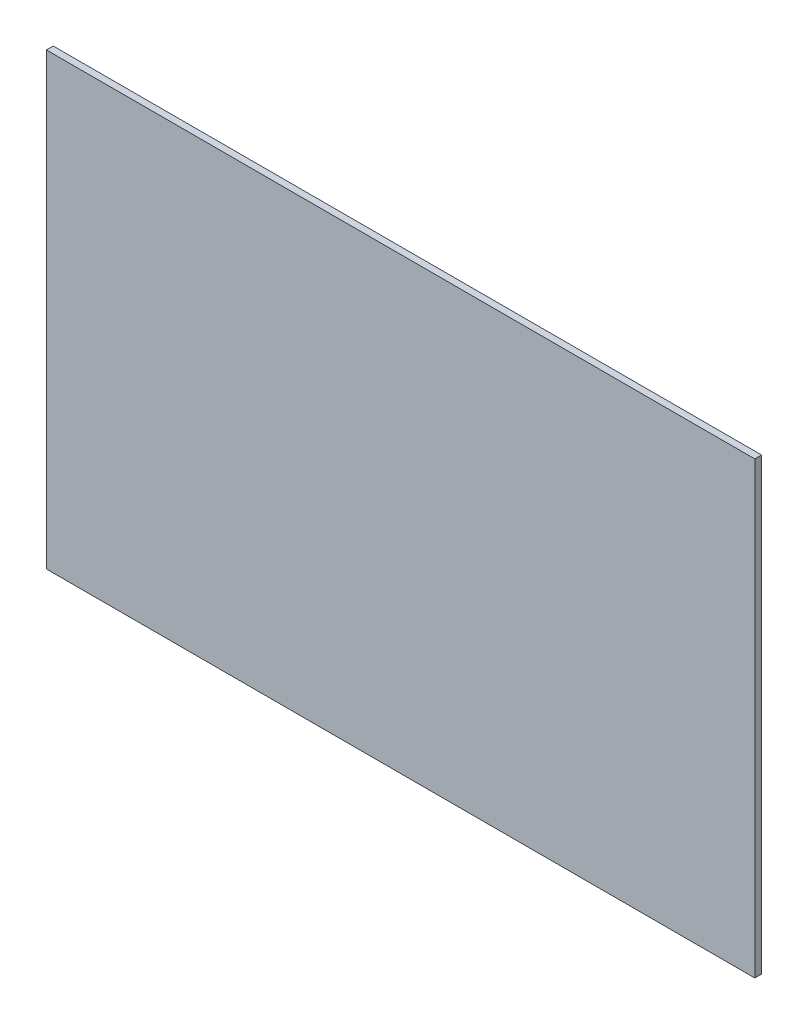
from build123d import *

# Parameters (mm, degrees)
ESQUISSE1_W        = 520
ESQUISSE1_H        = 330
BOSS_EXTRU_1_DEPTH = 5


with BuildPart() as part:
    # Esquisse1 → Boss.-Extru.1 (new body)
    with BuildSketch(Plane.XY):
        with Locations((52.010164835, 71.461172161)):
            Rectangle(ESQUISSE1_W, ESQUISSE1_H)
    extrude(amount=BOSS_EXTRU_1_DEPTH)


solid = part.part
